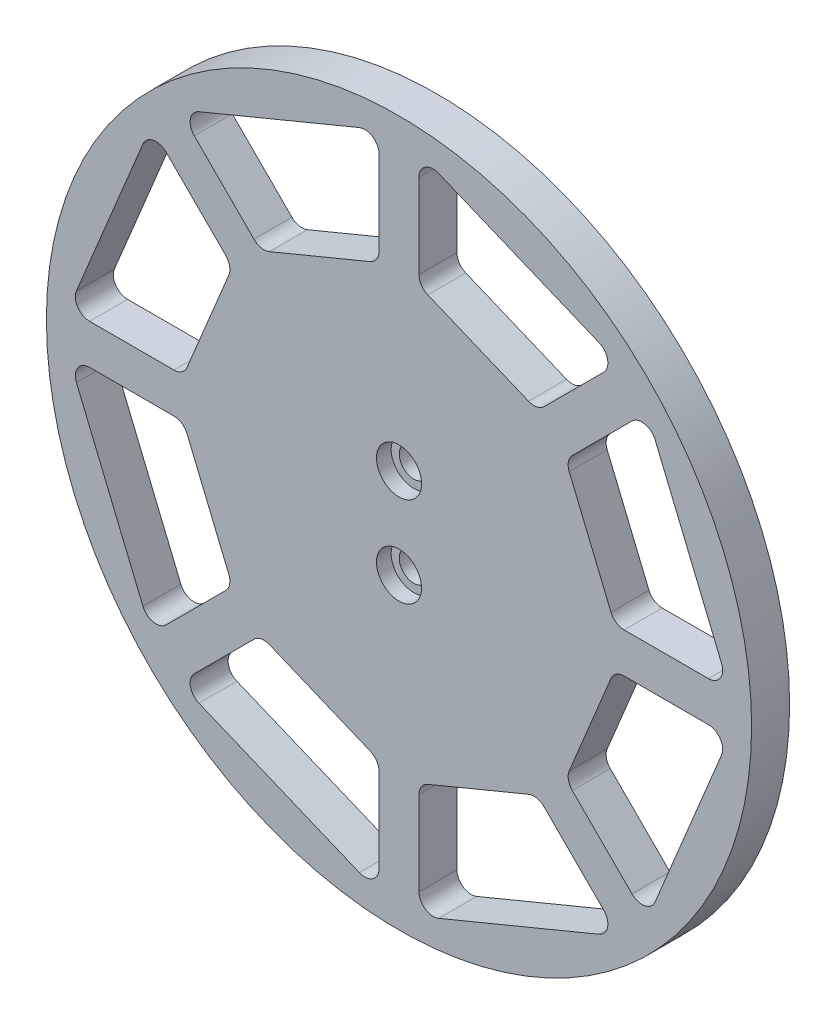
from build123d import *

# Parameters (mm, degrees)
SKETCH1_R           = 74.25
SKETCH1_R_2         = 3.05
BOSS_EXTRUDE1_DEPTH = 8
SKETCH2_R           = 4.75
CUT_EXTRUDE1_DEPTH  = 3.1


with BuildPart() as part:
    # Sketch1 → Boss-Extrude1 (new body)
    with BuildSketch(Plane.XY):
        Circle(SKETCH1_R)
        with Locations((0, 9.5)):
            Circle(SKETCH1_R_2, mode=Mode.SUBTRACT)
        with Locations((0, -9.5)):
            Circle(SKETCH1_R_2, mode=Mode.SUBTRACT)
        with BuildLine():
            Line((67.925889957, 8.348050297), (53.933820381, 42.127894432))
            ThreePointArc((53.933820381, 42.127894432), (51.74745275, 43.922199976), (49.04086144, 43.101164478))
            Line((49.04086144, 43.101164478), (36.488844859, 30.549147897))
            ThreePointArc((36.488844859, 30.549147897), (35.667809361, 29.013098519), (35.838526605, 27.279777256))
            Line((35.838526605, 27.279777256), (44.631380677, 6.051949703))
            ThreePointArc((44.631380677, 6.051949703), (45.736308575, 4.705591163), (47.403019275, 4.2))
            Line((47.403019275, 4.2), (65.154251359, 4.2))
            ThreePointArc((65.154251359, 4.2), (67.648660196, 5.533289301), (67.925889957, 8.348050297))
        make_face(mode=Mode.SUBTRACT)
        with BuildLine():
            Line((42.127894432, 53.933820381), (8.348050297, 67.925889957))
            ThreePointArc((8.348050297, 67.925889957), (5.533289301, 67.648660196), (4.2, 65.154251359))
            Line((4.2, 65.154251359), (4.2, 47.403019275))
            ThreePointArc((4.2, 47.403019275), (4.705591163, 45.736308575), (6.051949703, 44.631380677))
            Line((6.051949703, 44.631380677), (27.279777256, 35.838526605))
            ThreePointArc((27.279777256, 35.838526605), (29.013098519, 35.667809361), (30.549147897, 36.488844859))
            Line((30.549147897, 36.488844859), (43.101164478, 49.04086144))
            ThreePointArc((43.101164478, 49.04086144), (43.922199976, 51.74745275), (42.127894432, 53.933820381))
        make_face(mode=Mode.SUBTRACT)
        with BuildLine():
            Line((-8.348050297, 67.925889957), (-42.127894432, 53.933820381))
            ThreePointArc((-42.127894432, 53.933820381), (-43.922199976, 51.74745275), (-43.101164478, 49.04086144))
            Line((-43.101164478, 49.04086144), (-30.549147897, 36.488844859))
            ThreePointArc((-30.549147897, 36.488844859), (-29.013098519, 35.667809361), (-27.279777256, 35.838526605))
            Line((-27.279777256, 35.838526605), (-6.051949703, 44.631380677))
            ThreePointArc((-6.051949703, 44.631380677), (-4.705591163, 45.736308575), (-4.2, 47.403019275))
            Line((-4.2, 47.403019275), (-4.2, 65.154251359))
            ThreePointArc((-4.2, 65.154251359), (-5.533289301, 67.648660196), (-8.348050297, 67.925889957))
        make_face(mode=Mode.SUBTRACT)
        with BuildLine():
            Line((-53.933820381, 42.127894432), (-67.925889957, 8.348050297))
            ThreePointArc((-67.925889957, 8.348050297), (-67.648660196, 5.533289301), (-65.154251359, 4.2))
            Line((-65.154251359, 4.2), (-47.403019275, 4.2))
            ThreePointArc((-47.403019275, 4.2), (-45.736308575, 4.705591163), (-44.631380677, 6.051949703))
            Line((-44.631380677, 6.051949703), (-35.838526605, 27.279777256))
            ThreePointArc((-35.838526605, 27.279777256), (-35.667809361, 29.013098519), (-36.488844859, 30.549147897))
            Line((-36.488844859, 30.549147897), (-49.04086144, 43.101164478))
            ThreePointArc((-49.04086144, 43.101164478), (-51.74745275, 43.922199976), (-53.933820381, 42.127894432))
        make_face(mode=Mode.SUBTRACT)
        with BuildLine():
            Line((-67.925889957, -8.348050297), (-53.933820381, -42.127894432))
            ThreePointArc((-53.933820381, -42.127894432), (-51.74745275, -43.922199976), (-49.04086144, -43.101164478))
            Line((-49.04086144, -43.101164478), (-36.488844859, -30.549147897))
            ThreePointArc((-36.488844859, -30.549147897), (-35.667809361, -29.013098519), (-35.838526605, -27.279777256))
            Line((-35.838526605, -27.279777256), (-44.631380677, -6.051949703))
            ThreePointArc((-44.631380677, -6.051949703), (-45.736308575, -4.705591163), (-47.403019275, -4.2))
            Line((-47.403019275, -4.2), (-65.154251359, -4.2))
            ThreePointArc((-65.154251359, -4.2), (-67.648660196, -5.533289301), (-67.925889957, -8.348050297))
        make_face(mode=Mode.SUBTRACT)
        with BuildLine():
            Line((-42.127894432, -53.933820381), (-8.348050297, -67.925889957))
            ThreePointArc((-8.348050297, -67.925889957), (-5.533289301, -67.648660196), (-4.2, -65.154251359))
            Line((-4.2, -65.154251359), (-4.2, -47.403019275))
            ThreePointArc((-4.2, -47.403019275), (-4.705591163, -45.736308575), (-6.051949703, -44.631380677))
            Line((-6.051949703, -44.631380677), (-27.279777256, -35.838526605))
            ThreePointArc((-27.279777256, -35.838526605), (-29.013098519, -35.667809361), (-30.549147897, -36.488844859))
            Line((-30.549147897, -36.488844859), (-43.101164478, -49.04086144))
            ThreePointArc((-43.101164478, -49.04086144), (-43.922199976, -51.74745275), (-42.127894432, -53.933820381))
        make_face(mode=Mode.SUBTRACT)
        with BuildLine():
            Line((8.348050297, -67.925889957), (42.127894432, -53.933820381))
            ThreePointArc((42.127894432, -53.933820381), (43.922199976, -51.74745275), (43.101164478, -49.04086144))
            Line((43.101164478, -49.04086144), (30.549147897, -36.488844859))
            ThreePointArc((30.549147897, -36.488844859), (29.013098519, -35.667809361), (27.279777256, -35.838526605))
            Line((27.279777256, -35.838526605), (6.051949703, -44.631380677))
            ThreePointArc((6.051949703, -44.631380677), (4.705591163, -45.736308575), (4.2, -47.403019275))
            Line((4.2, -47.403019275), (4.2, -65.154251359))
            ThreePointArc((4.2, -65.154251359), (5.533289301, -67.648660196), (8.348050297, -67.925889957))
        make_face(mode=Mode.SUBTRACT)
        with BuildLine():
            Line((53.933820381, -42.127894432), (67.925889957, -8.348050297))
            ThreePointArc((67.925889957, -8.348050297), (67.648660196, -5.533289301), (65.154251359, -4.2))
            Line((65.154251359, -4.2), (47.403019275, -4.2))
            ThreePointArc((47.403019275, -4.2), (45.736308575, -4.705591163), (44.631380677, -6.051949703))
            Line((44.631380677, -6.051949703), (35.838526605, -27.279777256))
            ThreePointArc((35.838526605, -27.279777256), (35.667809361, -29.013098519), (36.488844859, -30.549147897))
            Line((36.488844859, -30.549147897), (49.04086144, -43.101164478))
            ThreePointArc((49.04086144, -43.101164478), (51.74745275, -43.922199976), (53.933820381, -42.127894432))
        make_face(mode=Mode.SUBTRACT)
    extrude(amount=BOSS_EXTRUDE1_DEPTH)

    # Sketch2 → Cut-Extrude1 (cut)
    with BuildSketch(Plane.XY.offset(8)):
        with Locations((0, -9.5)):
            Circle(SKETCH2_R)
        with Locations((0, 9.5)):
            Circle(SKETCH2_R)
    extrude(amount=-CUT_EXTRUDE1_DEPTH, mode=Mode.SUBTRACT)


solid = part.part
